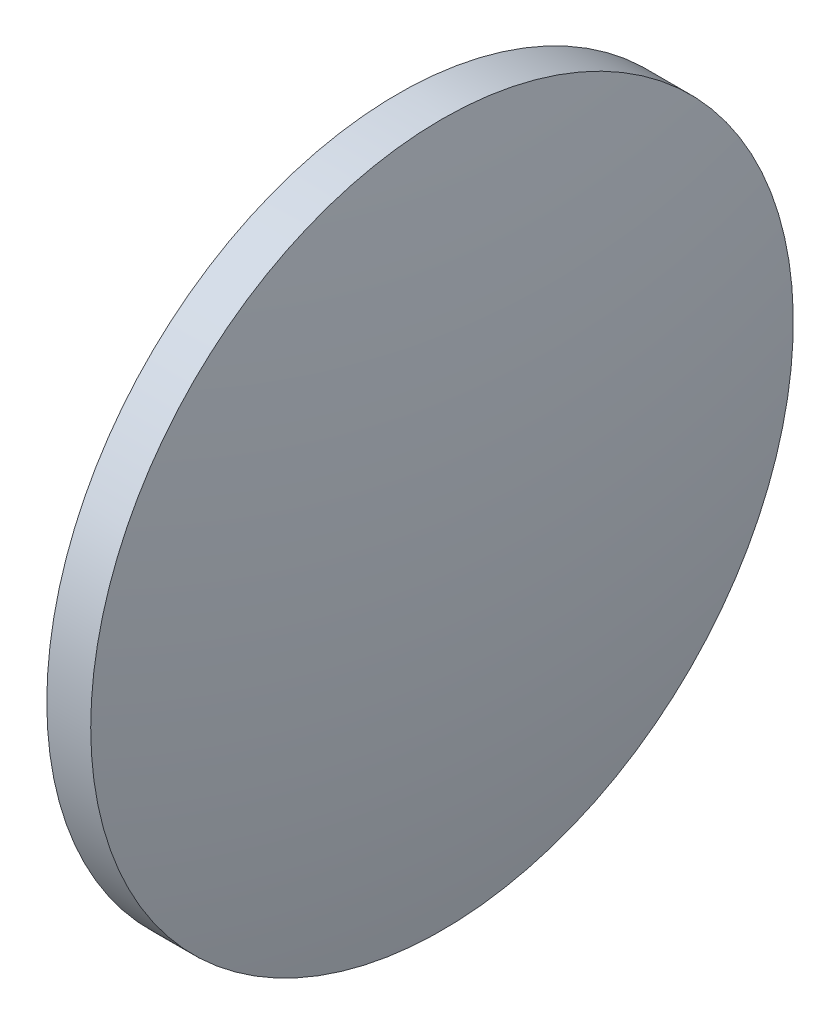
from build123d import *


with BuildPart() as part:
    # 草图1 → 旋转1 (revolve)
    with BuildSketch(Plane.XY):
        with BuildLine():
            Line((768.871982817, 193.849391549), (768.871982817, 213.849391549))
            Line((768.871982817, 213.849391549), (771.371982817, 213.849391549))
            ThreePointArc((771.371982817, 213.849391549), (772.833329717, 203.896810372), (773.321982817, 193.849391549))
            Line((773.321982817, 193.849391549), (768.871982817, 193.849391549))
        make_face()
    revolve(axis=Axis((764.177439637, 193.849391549, 0), (1, 0, 0)))


solid = part.part
